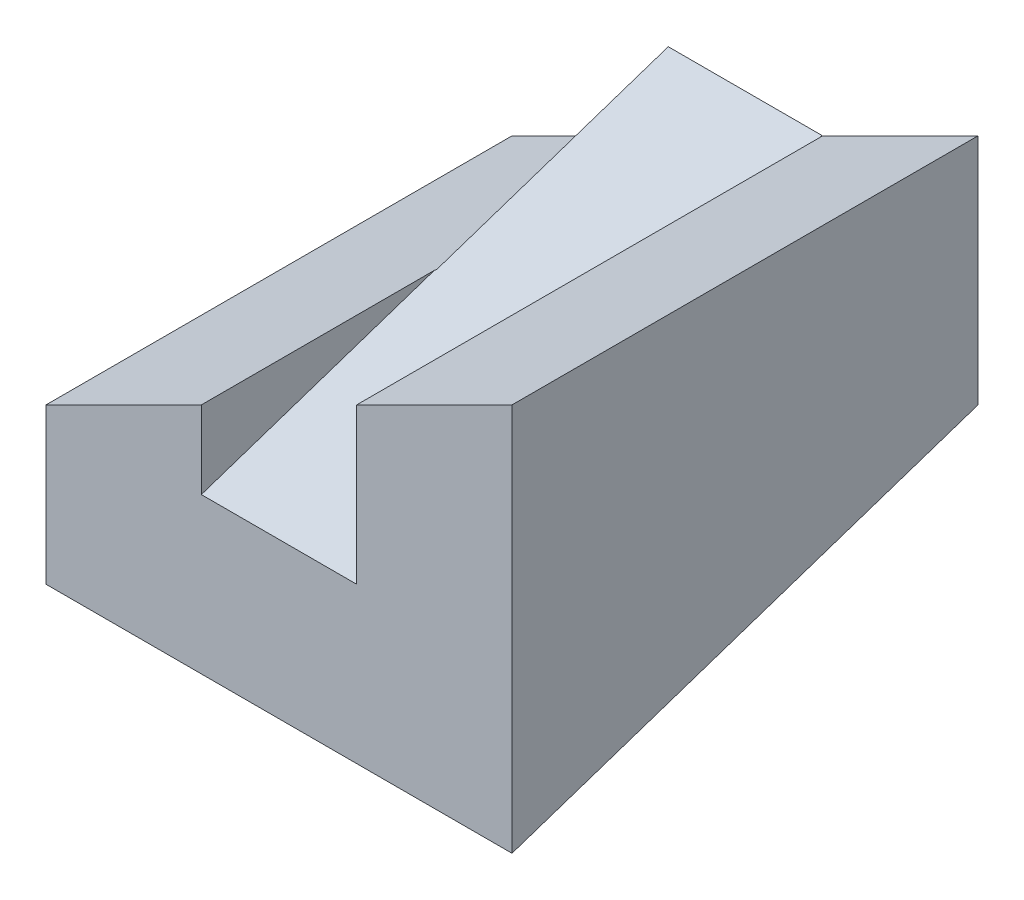
from build123d import *

# Parameters (mm, degrees)
SKETCH1_W           = 6
SKETCH1_H           = 6
BOSS_EXTRUDE1_DEPTH = 5
CUT_EXTRUDE12_DEPTH = 12
CUT_EXTRUDE13_DEPTH = 1
CUT_EXTRUDE14_DEPTH = 2


with BuildPart() as part:
    # Sketch1 → Boss-Extrude1 (new body)
    with BuildSketch(Plane(origin=(0, 0, 0), x_dir=(1, 0, 0), z_dir=(0, 1, 0))):
        Rectangle(SKETCH1_W, SKETCH1_H)
    extrude(amount=BOSS_EXTRUDE1_DEPTH)

    # Sketch11 → Cut-Extrude12 (cut)
    with BuildSketch(Plane.XY.offset(3)):
        Polygon((-3, 5), (-3, 2), (-0.98808733, 3.005956335), (-0.98808733, 4), (0.98808733, 4), (0.98808733, 3.994043665), (3, 5), align=None)
    extrude(amount=-CUT_EXTRUDE12_DEPTH, mode=Mode.SUBTRACT)

    # Sketch12 → Cut-Extrude13 (cut, symmetric)
    with BuildSketch(Plane(origin=(0, 0, 0), x_dir=(0, 0, -1), z_dir=(1, 0, 0))):
        Polygon((3, 4), (-3, 2), (-3, 3.005956335), (-3, 4), align=None)
    extrude(amount=CUT_EXTRUDE13_DEPTH, both=True, mode=Mode.SUBTRACT)

    # Sketch13 → Cut-Extrude14 (cut)
    with BuildSketch(Plane(origin=(3, 0, 0), x_dir=(0, 0, -1), z_dir=(1, 0, 0))):
        Polygon((3, 2), (-3, 0), (3, 0), align=None)
    extrude(amount=-CUT_EXTRUDE14_DEPTH, mode=Mode.SUBTRACT)


solid = part.part
